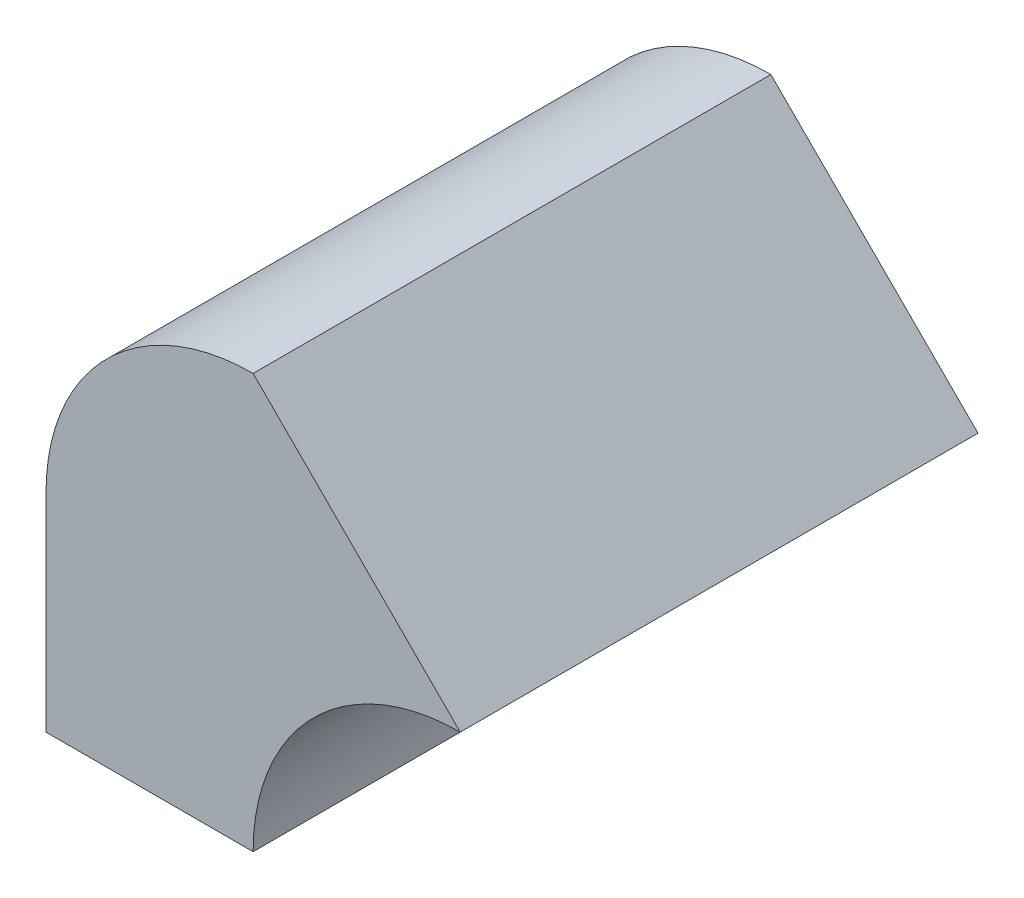
from build123d import *

# Parameters (mm, degrees)
BOSS_EXTRUDE1_DEPTH = 25


with BuildPart() as part:
    # Sketch1 → Boss-Extrude1 (new body)
    with BuildSketch(Plane.XY):
        with BuildLine():
            Line((0, -10), (0, 0))
            ThreePointArc((0, 0), (2.928932188, 7.071067812), (10, 10))
            Line((10, 10), (20, 0))
            ThreePointArc((20, 0), (12.928932188, -2.928932188), (10, -10))
            Line((10, -10), (0, -10))
        make_face()
    extrude(amount=BOSS_EXTRUDE1_DEPTH)


solid = part.part
